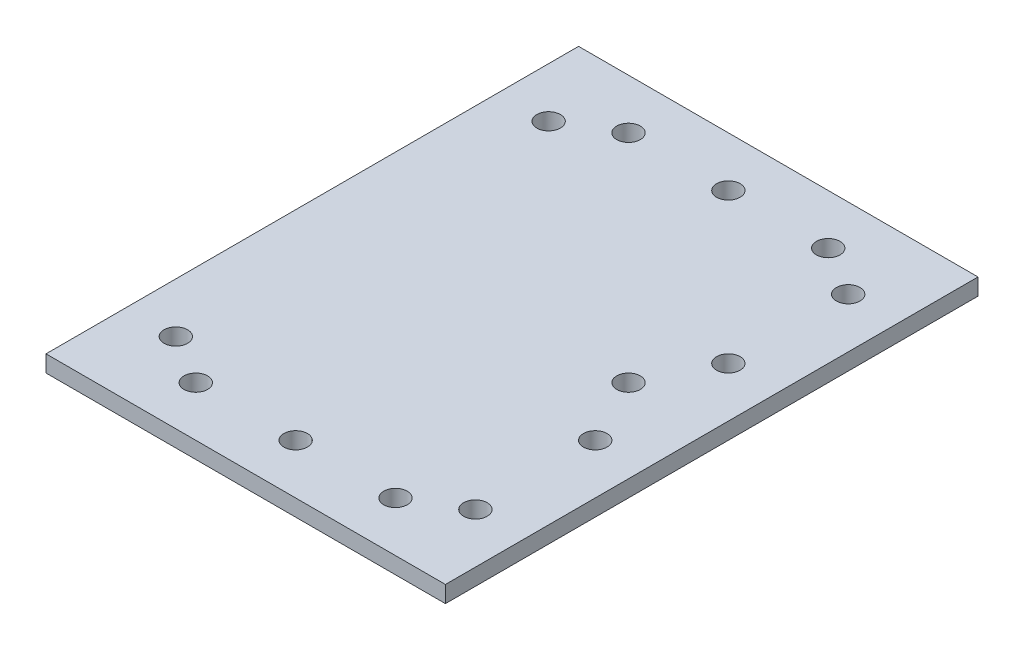
from build123d import *

# Parameters (mm, degrees)
SKETCH1_W           = 76.2
SKETCH1_H           = 101.6
SKETCH1_R           = 2.25
BOSS_EXTRUDE1_DEPTH = 3.175


with BuildPart() as part:
    # Sketch1 → Boss-Extrude1 (new body)
    with BuildSketch(Plane(origin=(0, 0, 0), x_dir=(1, 0, 0), z_dir=(0, 1, 0))):
        Rectangle(SKETCH1_W, SKETCH1_H)
        with Locations((-19.05, -41.275)):
            Circle(SKETCH1_R, mode=Mode.SUBTRACT)
        with Locations((19.05, -41.275)):
            Circle(SKETCH1_R, mode=Mode.SUBTRACT)
        with Locations((28.575, -35.56)):
            Circle(SKETCH1_R, mode=Mode.SUBTRACT)
        with Locations((-28.575, -35.56)):
            Circle(SKETCH1_R, mode=Mode.SUBTRACT)
        with Locations((28.575, 35.56)):
            Circle(SKETCH1_R, mode=Mode.SUBTRACT)
        with Locations((19.05, 41.275)):
            Circle(SKETCH1_R, mode=Mode.SUBTRACT)
        with Locations((-28.575, 35.56)):
            Circle(SKETCH1_R, mode=Mode.SUBTRACT)
        with Locations((-19.05, 41.275)):
            Circle(SKETCH1_R, mode=Mode.SUBTRACT)
        with Locations((0, -41.275)):
            Circle(SKETCH1_R, mode=Mode.SUBTRACT)
        with Locations((0, 41.275)):
            Circle(SKETCH1_R, mode=Mode.SUBTRACT)
        with Locations((28.575, 12.7)):
            Circle(SKETCH1_R, mode=Mode.SUBTRACT)
        with Locations((28.575, -12.7)):
            Circle(SKETCH1_R, mode=Mode.SUBTRACT)
        with Locations((22.23, 0)):
            Circle(SKETCH1_R, mode=Mode.SUBTRACT)
    extrude(amount=BOSS_EXTRUDE1_DEPTH)


solid = part.part
